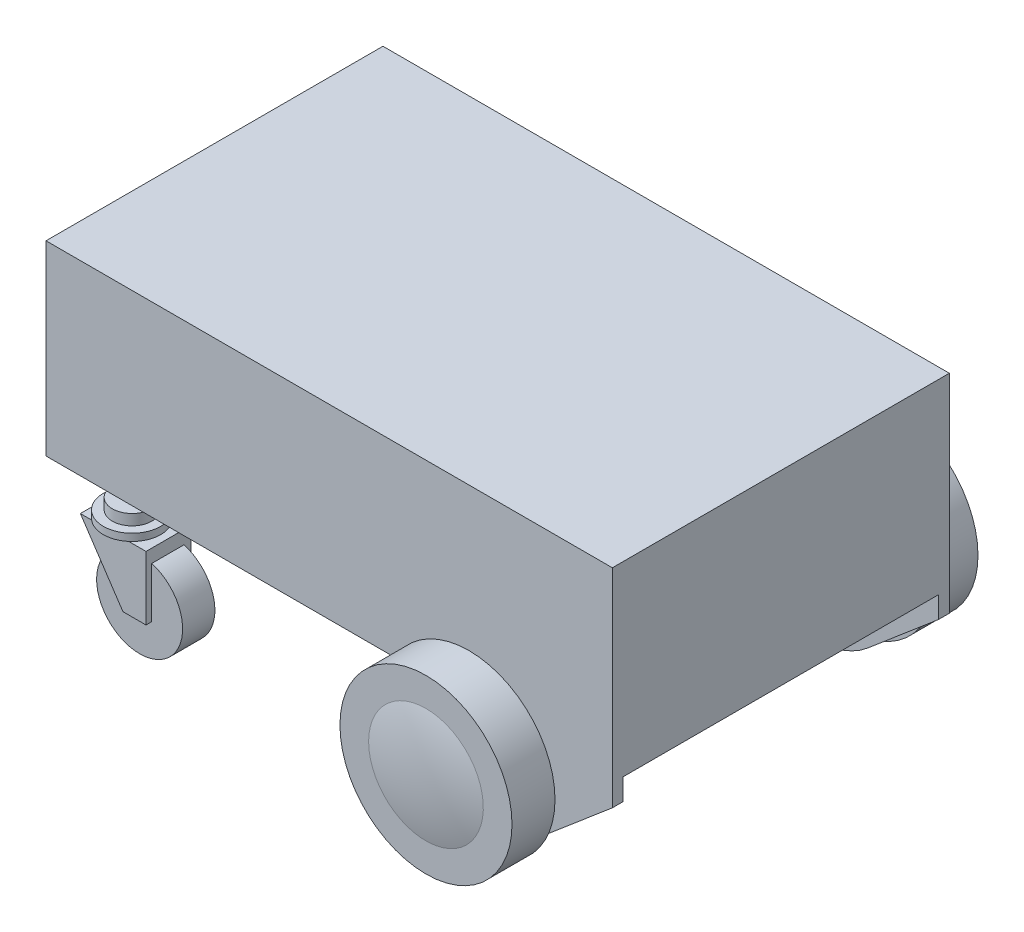
from build123d import *

# Parameters (mm, degrees)
BASE_EXTRUDE_DEPTH        = 470
CUT_EXTRUDE1_DEPTH        = 440
BOSS_EXTRUDE1_DEPTH       = 410
SKETCH6_R                 = 120
BOSS_EXTRUDE2_DEPTH       = 90
SKETCH7_R                 = 120
BOSS_EXTRUDE3_DEPTH       = 90
SKETCH8_R                 = 136.536471951
SKETCH8_R_2               = 70
CUT_EXTRUDE5_DEPTH        = 30
SKETCH9_R                 = 134.51242902
SKETCH9_R_2               = 70
CUT_EXTRUDE6_DEPTH        = 30
SKETCH11_R                = 27.5
BOSS_EXTRUDE4_DEPTH       = 15
SKETCH12_R                = 27.5
BOSS_EXTRUDE5_DEPTH       = 15
SKETCH13_R                = 40
BOSS_EXTRUDE6_DEPTH       = 10
SKETCH14_R                = 40
BOSS_EXTRUDE7_DEPTH       = 10
SKETCH15_W                = 100
SKETCH15_H                = 45
BOSS_EXTRUDE8_DEPTH       = 210
SKETCH16_W                = 100
SKETCH16_H                = 45
BOSS_EXTRUDE9_DEPTH       = 191.927006629
CUT_EXTRUDE8_DEPTH        = 573.5
SKETCH19_R                = 60
BOSS_EXTRUDE10_DEPTH      = 45
SKETCH20_R                = 60
BOSS_EXTRUDE11_DEPTH      = 45
BOSS_EXTRUDE12_DEPTH      = 8
BOSS_EXTRUDE12_DEPTH_BACK = 55
BOSS_EXTRUDE13_DEPTH      = 8
BOSS_EXTRUDE13_DEPTH_BACK = 52


with BuildPart() as part:
    # Sketch1 → Base-Extrude (new body)
    with BuildSketch(Plane.XY):
        with BuildLine():
            Line((0, 0), (0, 260))
            Line((0, 260), (790, 260))
            Line((790, 260), (790, -30))
            Line((790, -30), (691.176470588, -113.868409038))
            ThreePointArc((691.176470588, -113.868409038), (573.790757227, -129.823373427), (510, -30))
            Line((510, -30), (510, 0))
            Line((510, 0), (0, 0))
        make_face()
    extrude(amount=BASE_EXTRUDE_DEPTH)

    # Sketch2 → Cut-Extrude1 (cut)
    with BuildSketch(Plane.XY.offset(15)):
        with BuildLine():
            Line((500, 0), (545.838015129, 0))
            ThreePointArc((545.838015129, 0), (620, -110), (694.161984871, 0))
            Line((694.161984871, 0), (790, 0))
            Line((790, 0), (790, -150))
            Line((790, -150), (500, -150))
            Line((500, -150), (500, 0))
        make_face()
    extrude(amount=CUT_EXTRUDE1_DEPTH, mode=Mode.SUBTRACT)

    # Sketch3 → Boss-Extrude1 (add)
    with BuildSketch(Plane.XY.offset(30)):
        Polygon((540, -30), (540, -105.498344353), (540, -110), (620, -110), align=None)
    extrude(amount=BOSS_EXTRUDE1_DEPTH)

    # Sketch6 → Boss-Extrude2 (add)
    with BuildSketch(Plane.XY.offset(470)):
        with Locations(Location((620, -30, 0), (0, 0, 165.522487814))):  # turned: the seam where the file's is
            Circle(SKETCH6_R)
    extrude(amount=BOSS_EXTRUDE2_DEPTH)

    # Sketch7 → Boss-Extrude3 (add)
    with BuildSketch(Plane(origin=(0, 0, 0), x_dir=(-1, 0, 0), z_dir=(0, 0, -1))):
        with Locations(Location((-620, -30, 0), (0, 0, 14.477512186))):  # turned: the seam where the file's is
            Circle(SKETCH7_R)
    extrude(amount=BOSS_EXTRUDE3_DEPTH)

    # Sketch8 → Cut-Extrude5 (cut)
    with BuildSketch(Plane.XY.offset(470)):
        with Locations((620, -30)):
            Circle(SKETCH8_R)
        with Locations((620, -30)):
            Circle(SKETCH8_R_2, mode=Mode.SUBTRACT)
    extrude(amount=CUT_EXTRUDE5_DEPTH, mode=Mode.SUBTRACT)

    # Sketch9 → Cut-Extrude6 (cut)
    with BuildSketch(Plane(origin=(0, 0, 0), x_dir=(-1, 0, 0), z_dir=(0, 0, -1))):
        with Locations((-620, -30)):
            Circle(SKETCH9_R)
        with Locations(Location((-620, -30, 0), (0, 0, 180))):  # turned: the seam where the file's is
            Circle(SKETCH9_R_2, mode=Mode.SUBTRACT)
    extrude(amount=CUT_EXTRUDE6_DEPTH, mode=Mode.SUBTRACT)

    # Sketch11 → Boss-Extrude4 (add)
    with BuildSketch(Plane.XZ):
        with Locations(Location((110, 460, 0), (0, 0, 158.676313737))):  # turned: the seam where the file's is
            Circle(SKETCH11_R)
    extrude(amount=BOSS_EXTRUDE4_DEPTH)

    # Sketch12 → Boss-Extrude5 (add)
    with BuildSketch(Plane.XZ):
        with Locations(Location((110, 10, 0), (0, 0, 201.323686263))):  # turned: the seam where the file's is
            Circle(SKETCH12_R)
    extrude(amount=BOSS_EXTRUDE5_DEPTH)

    # Sketch13 → Boss-Extrude6 (add)
    with BuildSketch(Plane.XZ.offset(15)):
        with Locations(Location((110, 460, 0), (0, 0, 270))):  # turned: the seam where the file's is
            Circle(SKETCH13_R)
    extrude(amount=BOSS_EXTRUDE6_DEPTH)

    # Sketch14 → Boss-Extrude7 (add)
    with BuildSketch(Plane.XZ.offset(15)):
        with Locations(Location((110, 10, 0), (0, 0, 270))):  # turned: the seam where the file's is
            Circle(SKETCH14_R)
    extrude(amount=BOSS_EXTRUDE7_DEPTH)

    # Sketch15 → Boss-Extrude8 (add)
    with BuildSketch(Plane.XZ.offset(25)):
        with Locations((110, 10)):
            Rectangle(SKETCH15_W, SKETCH15_H)
    extrude(amount=BOSS_EXTRUDE8_DEPTH)

    # Sketch16 → Boss-Extrude9 (add)
    with BuildSketch(Plane.XZ.offset(25)):
        with Locations((110, 460)):
            Rectangle(SKETCH16_W, SKETCH16_H)
    extrude(amount=BOSS_EXTRUDE9_DEPTH)

    # Sketch17 → Cut-Extrude8 (cut, through all)
    with BuildSketch(Plane(origin=(0, 0, -12.5), x_dir=(-1, 0, 0), z_dir=(0, 0, -1))):
        Polygon((-68.464054306, -25), (-130, -120), (-160, -120), (-160, -140), (-180, -140), (-180, -240), (-48.040661319, -240), (-48.040661319, -25), align=None)
    extrude(amount=-CUT_EXTRUDE8_DEPTH, mode=Mode.SUBTRACT)

    # Sketch19 → Boss-Extrude10 (add)
    with BuildSketch(Plane(origin=(0, 0, -12.5), x_dir=(-1, 0, 0), z_dir=(0, 0, -1))):
        with Locations((-143.071891388, -101.075008075)):
            Circle(SKETCH19_R)
    extrude(amount=-BOSS_EXTRUDE10_DEPTH)

    # Sketch20 → Boss-Extrude11 (add)
    with BuildSketch(Plane.XY.offset(482.5)):
        with Locations((143.071891388, -101.075008075)):
            Circle(SKETCH20_R)
    extrude(amount=-BOSS_EXTRUDE11_DEPTH)

    # Sketch21 → Boss-Extrude12 (add, two sides)
    with BuildSketch(Plane.XY.offset(482.5)) as boss_extrude12_sk:
        Polygon((160, -25), (160, -113.868409038), (127.837584953, -113.868409038), (68.464054306, -25), align=None)
    extrude(amount=BOSS_EXTRUDE12_DEPTH)
    extrude(boss_extrude12_sk.sketch, amount=-BOSS_EXTRUDE12_DEPTH_BACK)

    # Sketch22 → Boss-Extrude13 (add, two sides)
    with BuildSketch(Plane(origin=(0, 0, -12.5), x_dir=(-1, 0, 0), z_dir=(0, 0, -1))) as boss_extrude13_sk:
        Polygon((-160, -25), (-160, -110), (-160, -113.868409038), (-127.837584953, -113.868409038), (-68.464054306, -25), align=None)
    extrude(amount=BOSS_EXTRUDE13_DEPTH)
    extrude(boss_extrude13_sk.sketch, amount=-BOSS_EXTRUDE13_DEPTH_BACK)

    # Sketch23 → Revolve1 (revolve)
    with BuildSketch(Plane(origin=(620, 0, 0), x_dir=(0, 0, -1), z_dir=(-1, 0, 0)), mode=Mode.PRIVATE) as revolve1_sk:
        with BuildLine():
            Line((-560, 30), (-570, 30))
            add(Edge.make_bspline(
                [(-570, 30), (-570, 2.901370053), (-566.915073502, -23.764728538), (-560, -50)],
                knots=[0, 0, 0, 0, 1, 1, 1, 1], degree=3))
            Line((-560, -50), (-560, 30))
        make_face()
    revolve1 = revolve(revolve1_sk.sketch.rotate(Axis((620, -30, 560), (0, 0, 1)), 270), axis=Axis((620, -30, 560), (0, 0, 1)))  # turned: the seam where the file's is

    # Mirror1: Revolve1 across plane
    add(revolve1.mirror(Plane(origin=(0, 0, 235), x_dir=(1, 0, 0), z_dir=(0, 0, -1))))


solid = part.part
